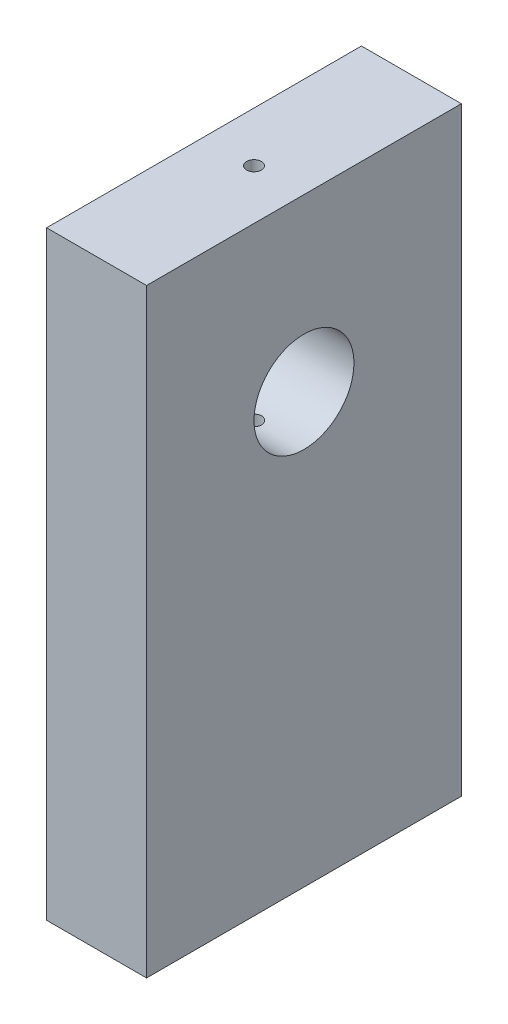
from build123d import *

# Parameters (mm, degrees)
SKETCH11_W          = 12.7
SKETCH11_H          = 40
BOSS_EXTRUDE2_DEPTH = 76.2
SKETCH12_R          = 6.35
CUT_EXTRUDE5_DEPTH  = 13.7
SKETCH13_R          = 0.95
CUT_EXTRUDE6_DEPTH  = 30
SKETCH17_R          = 0.95
CUT_EXTRUDE8_DEPTH  = 21


with BuildPart() as part:
    # Sketch11 → Boss-Extrude2 (new body)
    with BuildSketch(Plane(origin=(0, 0, 0), x_dir=(1, 0, 0), z_dir=(0, 1, 0))):
        with Locations((6.35, -8.031139822)):
            Rectangle(SKETCH11_W, SKETCH11_H)
    extrude(amount=BOSS_EXTRUDE2_DEPTH)

    # Sketch12 → Cut-Extrude5 (cut, through all)
    with BuildSketch(Plane(origin=(12.7, 0, 0), x_dir=(0, 0, -1), z_dir=(1, 0, 0))):
        with Locations((-8.031139822, 54.5)):
            Circle(SKETCH12_R)
    extrude(amount=-CUT_EXTRUDE5_DEPTH, mode=Mode.SUBTRACT)

    # Sketch13 → Cut-Extrude6 (cut)
    with BuildSketch(Plane(origin=(0, 76.2, 0), x_dir=(1, 0, 0), z_dir=(0, 1, 0))):
        with Locations((6.35, -8.031139822)):
            Circle(SKETCH13_R)
    extrude(amount=-CUT_EXTRUDE6_DEPTH, mode=Mode.SUBTRACT)

    # Sketch17 → Cut-Extrude8 (cut)
    with BuildSketch(Plane.XZ):
        with Locations((6.35, 14.698139822)):
            Circle(SKETCH17_R)
        with Locations((6.35, 1.364139822)):
            Circle(SKETCH17_R)
    extrude(amount=-CUT_EXTRUDE8_DEPTH, mode=Mode.SUBTRACT)


solid = part.part
